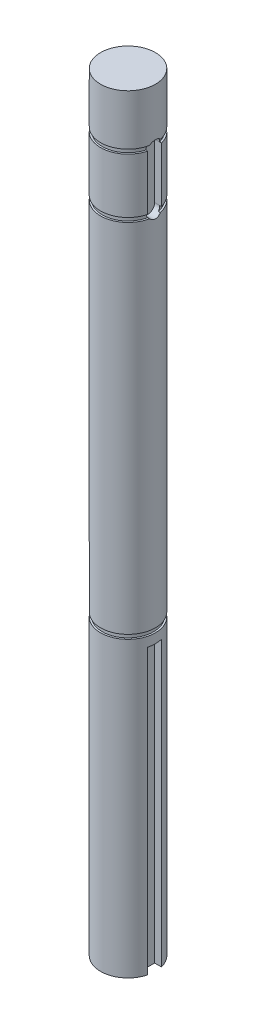
from build123d import *

# Parameters (mm, degrees)
SKETCH1_R           = 6.35
BOSS_EXTRUDE1_DEPTH = 177.8
SKETCH2_W           = 38.97891716
SKETCH2_H           = 0.9906
SKETCH3_W           = 26.12692973
SKETCH3_H           = 0.9906
SKETCH4_W           = 46.050080865
SKETCH4_H           = 0.9906
CUT_EXTRUDE1_DEPTH  = 1.778
SKETCH6_W           = 3.175
SKETCH6_H           = 80.766552272
CUT_EXTRUDE2_DEPTH  = 1.778


with BuildPart() as part:
    # Sketch1 → Boss-Extrude1 (new body)
    with BuildSketch(Plane(origin=(0, 0, 0), x_dir=(1, 0, 0), z_dir=(0, 1, 0))):
        Circle(SKETCH1_R)
    extrude(amount=BOSS_EXTRUDE1_DEPTH)

    # Sketch2 → Cut-Revolve1 (revolve, cut)
    with BuildSketch(Plane(origin=(0, 0, 0), x_dir=(0, 0, -1), z_dir=(1, 0, 0))):
        with Locations((-25.43305858, 165.5953)):
            Rectangle(SKETCH2_W, SKETCH2_H)
    revolve(axis=Axis((0, 174.664052397, 0), (0, -1, 0)), mode=Mode.SUBTRACT)

    # Sketch3 → Cut-Revolve2 (revolve, cut)
    with BuildSketch(Plane(origin=(0, 0, 0), x_dir=(0, 0, -1), z_dir=(1, 0, 0))):
        with Locations((-19.007064865, 151.9047)):
            Rectangle(SKETCH3_W, SKETCH3_H)
    revolve(axis=Axis((0, 162.013911259, 0), (0, -1, 0)), mode=Mode.SUBTRACT)

    # Sketch4 → Cut-Revolve3 (revolve, cut)
    with BuildSketch(Plane(origin=(0, 0, 0), x_dir=(0, 0, -1), z_dir=(1, 0, 0))):
        with Locations((-28.968640433, 68.3641)):
            Rectangle(SKETCH4_W, SKETCH4_H)
    revolve(axis=Axis((0, 70.295355643, 0), (0, -1, 0)), mode=Mode.SUBTRACT)

    # Sketch5 → Cut-Extrude1 (cut)
    with BuildSketch(Plane(origin=(6.35, 0, 0), x_dir=(0, 0, -1), z_dir=(1, 0, 0))):
        with BuildLine():
            Line((1.5875, 165.1), (1.5875, 152.4))
            ThreePointArc((1.5875, 152.4), (0, 150.8125), (-1.5875, 152.4))
            Line((-1.5875, 152.4), (-1.5875, 165.1))
            ThreePointArc((-1.5875, 165.1), (0, 166.6875), (1.5875, 165.1))
        make_face()
    extrude(amount=-CUT_EXTRUDE1_DEPTH, mode=Mode.SUBTRACT)

    # Sketch6 → Cut-Extrude2 (cut)
    with BuildSketch(Plane(origin=(6.35, 0, 0), x_dir=(0, 0, -1), z_dir=(1, 0, 0))):
        with Locations((0, 25.301123864)):
            Rectangle(SKETCH6_W, SKETCH6_H)
    extrude(amount=-CUT_EXTRUDE2_DEPTH, mode=Mode.SUBTRACT)


solid = part.part
